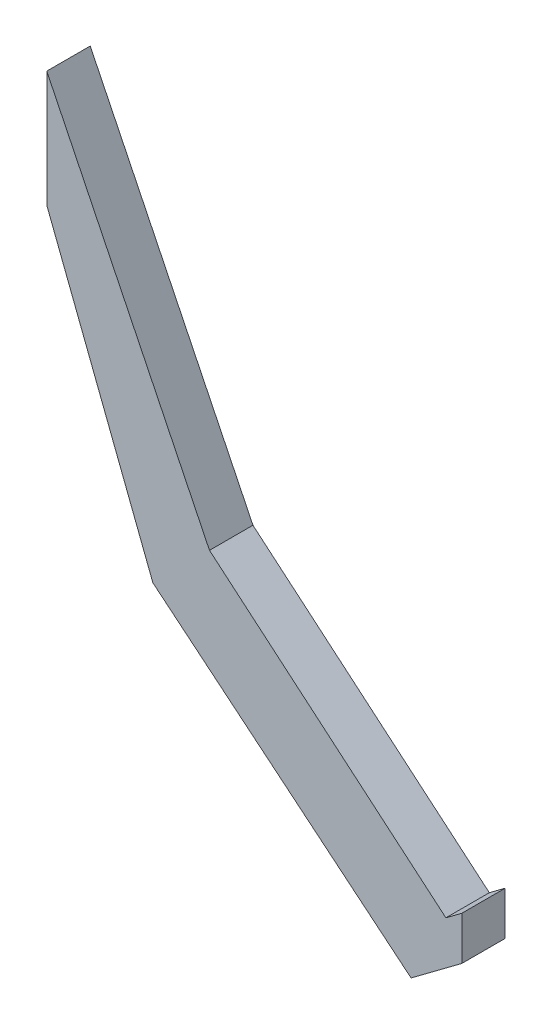
from build123d import *

# Parameters (mm, degrees)
SALIENTE_EXTRUIR1_DEPTH = 5


with BuildPart() as part:
    # Croquis1 → Saliente-Extruir1 (new body)
    with BuildSketch(Plane.XY):
        Polygon((-2.523567422, -23.017874122), (-0.693903445, -21.649603669), (-0.693903445, -26.656094086), (-6.529092756, -31.019800875), (-36.240038447, -6.492170482), (-48.451057668, 25.038640576), (-48.451057668, 38.396793067), (-29.726509063, 0), align=None)
    extrude(amount=SALIENTE_EXTRUIR1_DEPTH)


solid = part.part
